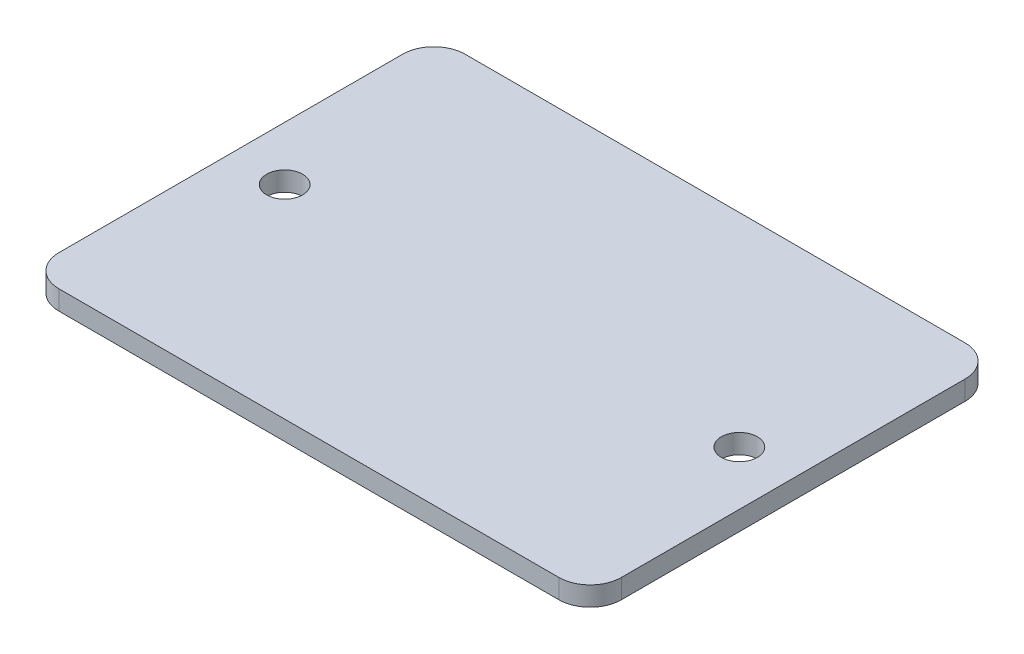
from build123d import *

# Parameters (mm, degrees)
SKETCH1_W           = 45.72
SKETCH1_H           = 33.02
BOSS_EXTRUDE1_DEPTH = 1.5748
FILLET1_R           = 2.54
SKETCH2_R           = 1.4605
CUT_EXTRUDE1_DEPTH  = 2.5748


with BuildPart() as part:
    # Sketch1 → Boss-Extrude1 (new body)
    with BuildSketch(Plane(origin=(0, 0, 0), x_dir=(1, 0, 0), z_dir=(0, 1, 0))):
        Rectangle(SKETCH1_W, SKETCH1_H)
    extrude(amount=BOSS_EXTRUDE1_DEPTH)

    # Fillet1
    fillet1_edges = [part.edges().sort_by_distance(p)[0] for p in [
        (-22.86, 0.7874, -16.51),
        (22.86, 0.7874, -16.51),
        (22.86, 0.7874, 16.51),
        (-22.86, 0.7874, 16.51),
    ]]
    fillet(fillet1_edges, radius=FILLET1_R)

    # Sketch2 → Cut-Extrude1 (cut, through all)
    with BuildSketch(Plane(origin=(0, 1.5748, 0), x_dir=(1, 0, 0), z_dir=(0, 1, 0))):
        with Locations((-18.4785, 0)):
            Circle(SKETCH2_R)
        with Locations((18.4785, 0)):
            Circle(SKETCH2_R)
    extrude(amount=-CUT_EXTRUDE1_DEPTH, mode=Mode.SUBTRACT)


solid = part.part
